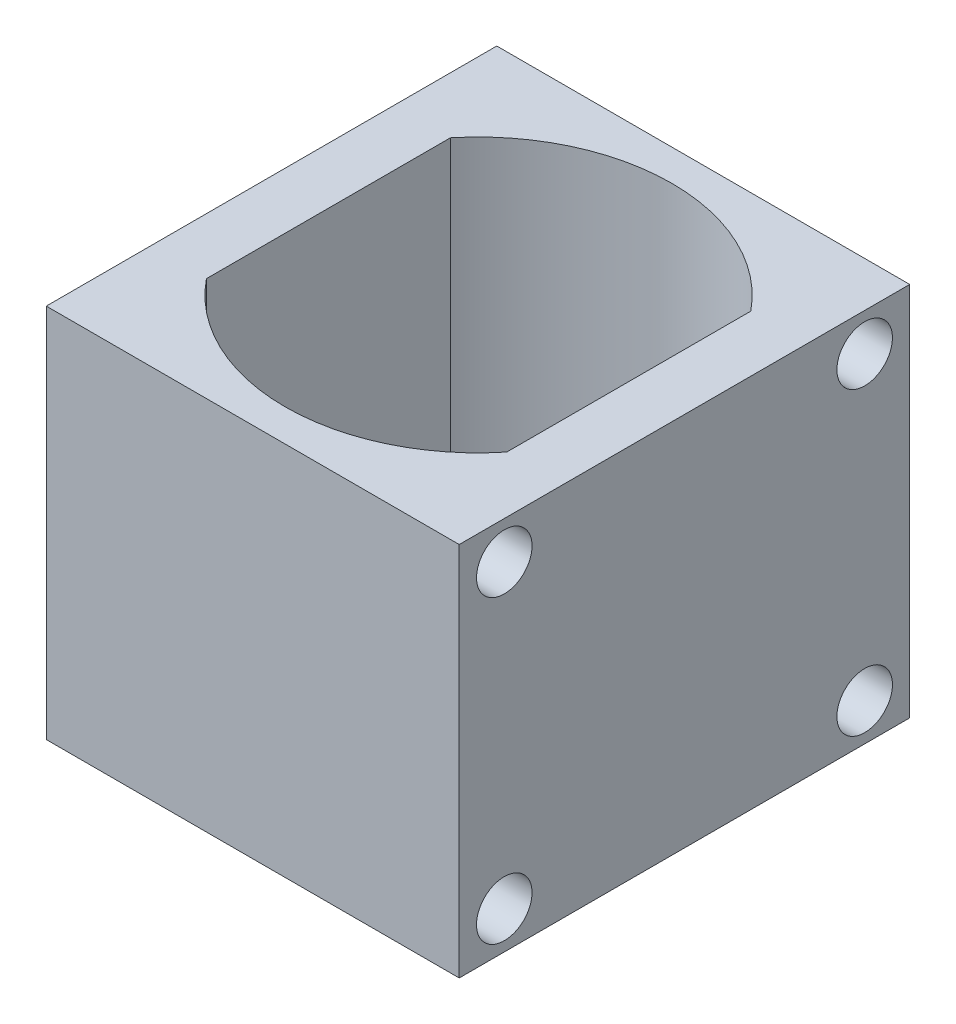
from build123d import *

# Parameters (mm, degrees)
BOSS_EXTRUDE1_DEPTH = 20
SKETCH2_R           = 1.48
CUT_EXTRUDE1_DEPTH  = 3


with BuildPart() as part:
    # Sketch1 → Boss-Extrude1 (new body)
    with BuildSketch(Plane(origin=(0, 0, 0), x_dir=(1, 0, 0), z_dir=(0, 1, 0))):
        Polygon((-11, 0), (-11, 12), (11, 12), (11, -12), (-11, -12), align=None)
        with BuildLine():
            Line((-8, 6.532500515), (-8, -6.467499485))
            ThreePointArc((-8, -6.467499485), (0, -10.287300403), (8, -6.467499485))
            Line((8, -6.467499485), (8, 6.532500515))
            ThreePointArc((8, 6.532500515), (0, 10.328289451), (-8, 6.532500515))
        make_face(mode=Mode.SUBTRACT)
    extrude(amount=BOSS_EXTRUDE1_DEPTH)

    # Sketch2 → Cut-Extrude1 (cut)
    with BuildSketch(Plane(origin=(11, 0, 0), x_dir=(0, 0, -1), z_dir=(1, 0, 0))):
        with Locations((-9.6, 18)):
            Circle(SKETCH2_R)
        with Locations((9.6, 18)):
            Circle(SKETCH2_R)
        with Locations((9.6, 2)):
            Circle(SKETCH2_R)
        with Locations((-9.6, 2)):
            Circle(SKETCH2_R)
    extrude(amount=-CUT_EXTRUDE1_DEPTH, mode=Mode.SUBTRACT)


solid = part.part
